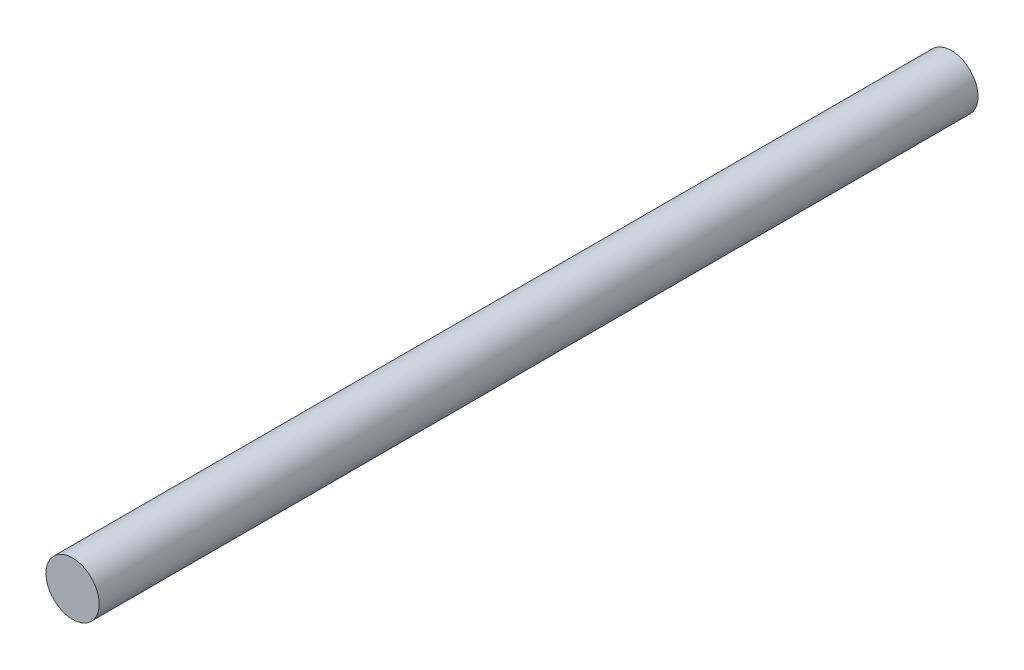
from build123d import *

# Parameters (mm, degrees)
SKETCH1_R           = 13.847107225
BOSS_EXTRUDE3_DEPTH = 457.2


with BuildPart() as part:
    # Sketch1 → Boss-Extrude3 (new body)
    with BuildSketch(Plane.XY):
        Circle(SKETCH1_R)
    extrude(amount=BOSS_EXTRUDE3_DEPTH)


solid = part.part
